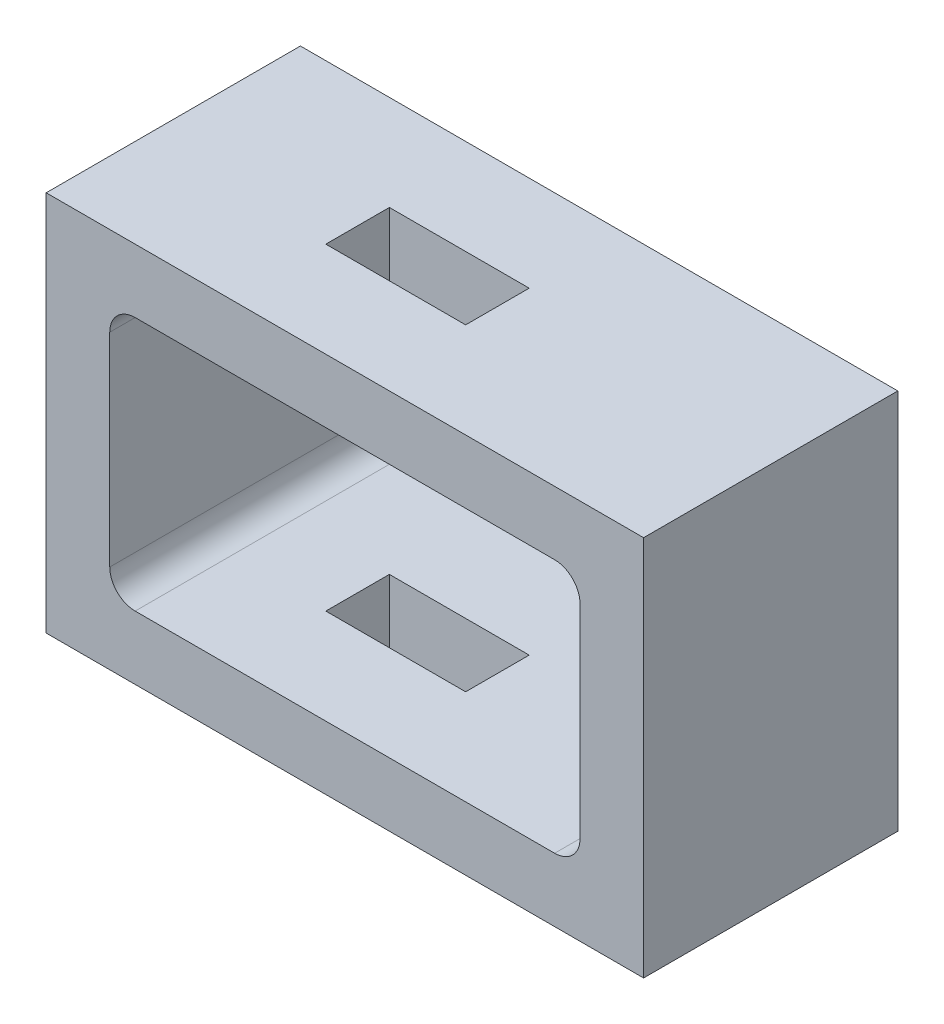
from build123d import *

# Parameters (mm, degrees)
EXTRUDE_1_DEPTH     = 20
FILLET_1_R          = 2
SKETCH_3_W          = 11
SKETCH_3_H          = 5
CUT_EXTRUDE_3_DEPTH = 44.037774106


with BuildPart() as part:
    # Эскиз1 → Бобышка-Вытянуть1 (new body)
    with BuildSketch(Plane.XY):
        Polygon((0, 15), (-23.5, 15), (-23.5, -15), (0, -15), (0, -10), (-18.5, -10), (-18.5, 10), (0, 10), align=None)
    extrude(amount=EXTRUDE_1_DEPTH)

    # Скругление1
    fillet_1_edges = [part.edges().sort_by_distance(p)[0] for p in [
        (-18.5, -10, 10),
        (-18.5, 10, 10),
    ]]
    fillet(fillet_1_edges, radius=FILLET_1_R)

    # Зеркальное отражение1: part across plane


with BuildPart() as part_1:
    add(part.part)
    add(part.part.mirror(Plane(origin=(0, 0, 20), x_dir=(0, 0, 1), z_dir=(1, 0, 0))))

    # Эскиз3 → Вырез-Вытянуть3 (cut, through all)
    with BuildSketch(Plane(origin=(0, 15, 0), x_dir=(1, 0, 0), z_dir=(0, 1, 0))):
        with Locations((-3.5, -10)):
            Rectangle(SKETCH_3_W, SKETCH_3_H)
    extrude(amount=-CUT_EXTRUDE_3_DEPTH, mode=Mode.SUBTRACT)


solid = part_1.part
